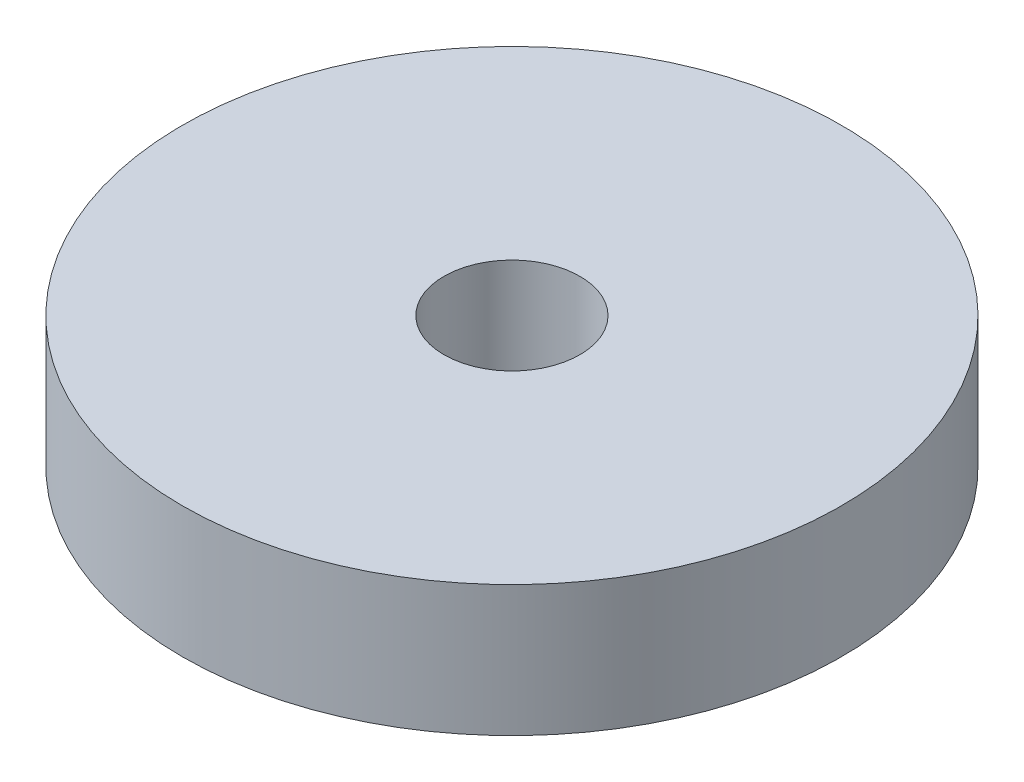
from build123d import *

# Parameters (mm, degrees)
SKETCH1_R           = 8
SKETCH1_R_2         = 1.65
BOSS_EXTRUDE1_DEPTH = 3.175


with BuildPart() as part:
    # Sketch1 → Boss-Extrude1 (new body)
    with BuildSketch(Plane(origin=(0, 0, 0), x_dir=(1, 0, 0), z_dir=(0, 1, 0))):
        Circle(SKETCH1_R)
        Circle(SKETCH1_R_2, mode=Mode.SUBTRACT)
    extrude(amount=BOSS_EXTRUDE1_DEPTH)


solid = part.part
